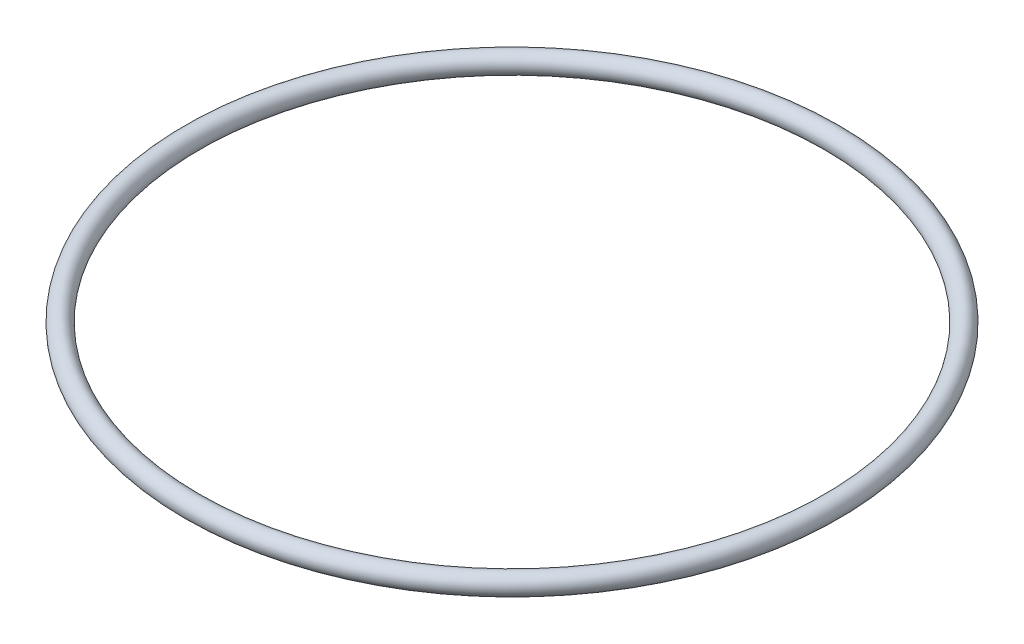
from build123d import *

# Parameters (mm, degrees)
SWEEP2_PROFILE_R = 1.5875


with BuildPart() as part:
    # Sweep2: sweep along a path in Sketch2
    with BuildLine(Plane(origin=(0, 0, 0), x_dir=(1, 0, 0), z_dir=(0, 1, 0))) as sweep2_path:
        CenterArc((0, 0), 50.8, 0, 360)
    # Sweep2 profile (on start of the path) → Sweep2 (sweep)
    with BuildSketch(Plane(origin=(50.8, 0, 0), x_dir=(-1, 0, 0), z_dir=(0, 0, -1))):
        Circle(SWEEP2_PROFILE_R)
    sweep(path=sweep2_path.line)


solid = part.part
